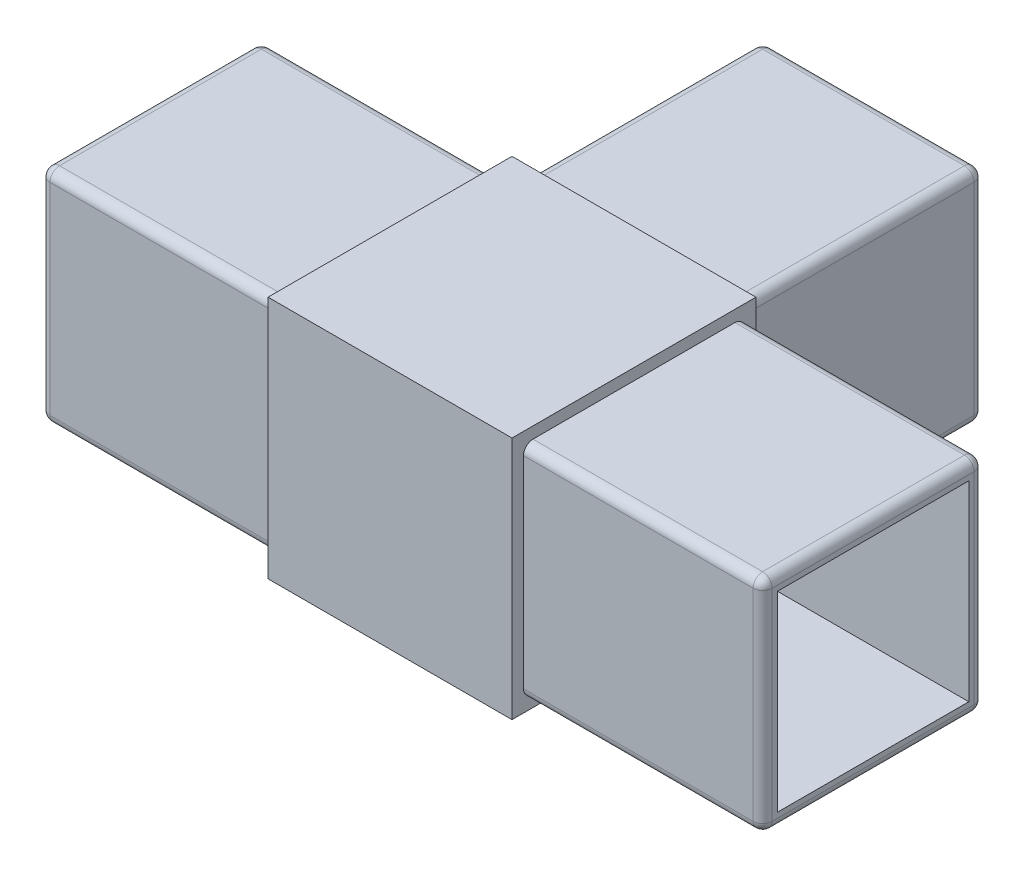
from build123d import *

# Parameters (mm, degrees)
SKETCH1_W           = 25
SKETCH1_H           = 23.1
SKETCH1_W_2         = 23.1
SKETCH1_H_2         = 25
BOSS_EXTRUDE2_DEPTH = 25.5
SKETCH2_W           = 23.1
SKETCH2_H           = 1.2
CUT_EXTRUDE1_DEPTH  = 25
SKETCH3_W           = 23.1
SKETCH3_H           = 1.2
CUT_EXTRUDE2_DEPTH  = 25
SKETCH4_W           = 23.1
SKETCH4_H           = 1.2
CUT_EXTRUDE3_DEPTH  = 25
SKETCH5_W           = 20
SKETCH5_H           = 20
CUT_EXTRUDE4_DEPTH  = 76.5
SKETCH8_W           = 20
SKETCH8_H           = 20
CUT_EXTRUDE5_DEPTH  = 30
FILLET1_R           = 1


with BuildPart() as part:
    # Sketch1 → Boss-Extrude2 (new body)
    with BuildSketch(Plane(origin=(0, 0, 0), x_dir=(1, 0, 0), z_dir=(0, 1, 0))):
        with Locations((-25.25, 0)):
            Rectangle(SKETCH1_W, SKETCH1_H)
        Polygon((11.55, 12.75), (-11.55, 12.75), (-12.75, 12.75), (-12.75, 11.55), (-12.75, -11.55), (-12.75, -12.75), (12.75, -12.75), (12.75, -11.55), (12.75, 11.55), (12.75, 12.75), align=None)
        with Locations((0, 25.25)):
            Rectangle(SKETCH1_W_2, SKETCH1_H_2)
        with Locations((25.25, 0)):
            Rectangle(SKETCH1_W, SKETCH1_H)
    extrude(amount=BOSS_EXTRUDE2_DEPTH)

    # Sketch2 → Cut-Extrude1 (cut)
    with BuildSketch(Plane(origin=(37.75, 0, 0), x_dir=(0, 0, -1), z_dir=(1, 0, 0))):
        with Locations((0, 24.9)):
            Rectangle(SKETCH2_W, SKETCH2_H)
        with Locations((0, 0.6)):
            Rectangle(SKETCH2_W, SKETCH2_H)
    extrude(amount=-CUT_EXTRUDE1_DEPTH, mode=Mode.SUBTRACT)

    # Sketch3 → Cut-Extrude2 (cut)
    with BuildSketch(Plane.ZY.offset(37.75)):
        with Locations((0, 24.9)):
            Rectangle(SKETCH3_W, SKETCH3_H)
        with Locations((0, 0.6)):
            Rectangle(SKETCH3_W, SKETCH3_H)
    extrude(amount=-CUT_EXTRUDE2_DEPTH, mode=Mode.SUBTRACT)

    # Sketch4 → Cut-Extrude3 (cut)
    with BuildSketch(Plane(origin=(0, 0, -37.75), x_dir=(-1, 0, 0), z_dir=(0, 0, -1))):
        with Locations((0, 24.9)):
            Rectangle(SKETCH4_W, SKETCH4_H)
        with Locations((0, 0.6)):
            Rectangle(SKETCH4_W, SKETCH4_H)
    extrude(amount=-CUT_EXTRUDE3_DEPTH, mode=Mode.SUBTRACT)

    # Sketch5 → Cut-Extrude4 (cut, through all)
    with BuildSketch(Plane(origin=(37.75, 0, 0), x_dir=(0, 0, -1), z_dir=(1, 0, 0))):
        with Locations((0, 12.75)):
            Rectangle(SKETCH5_W, SKETCH5_H)
    extrude(amount=-CUT_EXTRUDE4_DEPTH, mode=Mode.SUBTRACT)

    # Sketch8 → Cut-Extrude5 (cut)
    with BuildSketch(Plane(origin=(0, 0, -37.75), x_dir=(-1, 0, 0), z_dir=(0, 0, -1))):
        with Locations((0, 12.75)):
            Rectangle(SKETCH8_W, SKETCH8_H)
    extrude(amount=-CUT_EXTRUDE5_DEPTH, mode=Mode.SUBTRACT)

    # Fillet1
    fillet1_edges = [part.edges().sort_by_distance(p)[0] for p in [
        (25.25, 1.2, 11.55),
        (37.75, 1.2, 0),
        (-37.75, 12.75, 11.55),
        (-37.75, 12.75, -11.55),
        (-25.25, 24.3, -11.55),
        (-25.25, 24.3, 11.55),
        (-37.75, 24.3, 0),
        (-25.25, 1.2, 11.55),
        (-25.25, 1.2, -11.55),
        (-37.75, 1.2, 0),
        (-11.55, 12.75, -37.75),
        (11.55, 12.75, -37.75),
        (11.55, 24.3, -25.25),
        (-11.55, 24.3, -25.25),
        (0, 24.3, -37.75),
        (-11.55, 1.2, -25.25),
        (11.55, 1.2, -25.25),
        (0, 1.2, -37.75),
        (37.75, 12.75, -11.55),
        (37.75, 12.75, 11.55),
        (25.25, 24.3, 11.55),
        (25.25, 24.3, -11.55),
        (37.75, 24.3, 0),
        (25.25, 1.2, -11.55),
    ]]
    fillet(fillet1_edges, radius=FILLET1_R)


solid = part.part
